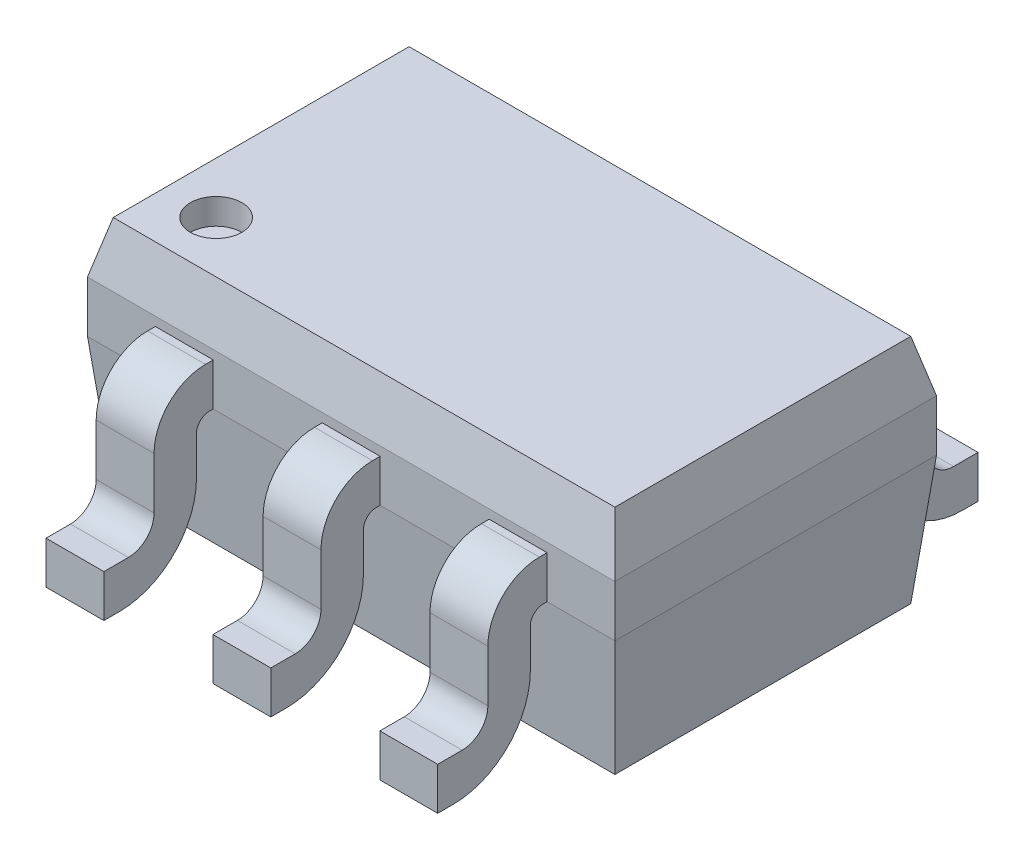
from build123d import *

# Parameters (mm, degrees)
SKETCH1_W             = 2.05
SKETCH1_H             = 1.25
BOSS_EXTRUDE1_DEPTH   = 0.9
BOSS_EXTRUDE2_START   = -1.025
BOSS_EXTRUDE2_DEPTH   = 0.76125
BOSS_EXTRUDE2_2_DEPTH = 0.76125
SKETCH3_W             = 0.42375
SKETCH3_H             = 0.425
CUT_EXTRUDE2_DEPTH    = 0.9
CHAMFER1_SIZE         = 0.05
CHAMFER1_SIZE2        = 0.5
CHAMFER2_SIZE         = 0.2
CHAMFER2_SIZE2        = 0.05
CHAMFER2_PART_2_SIZE  = 0.2
CHAMFER2_PART_2_SIZE2 = 0.05
CHAMFER2_PART_3_SIZE  = 0.2
CHAMFER2_PART_3_SIZE2 = 0.05
CHAMFER2_PART_4_SIZE  = 0.2
CHAMFER2_PART_4_SIZE2 = 0.05
SKETCH4_R             = 0.1
CUT_EXTRUDE3_DEPTH    = 0.1


with BuildPart() as part:
    # Sketch1 → Boss-Extrude1 (new body)
    with BuildSketch(Plane(origin=(0, 0, 0), x_dir=(1, 0, 0), z_dir=(0, 1, 0))):
        Rectangle(SKETCH1_W, SKETCH1_H)
    extrude(amount=BOSS_EXTRUDE1_DEPTH)

    # Chamfer1
    chamfer1_edges = [part.edges().sort_by_distance(p)[0] for p in [
        (0, 0, 0.625),
        (-1.025, 0, 0),
        (0, 0, -0.625),
        (1.025, 0, 0),
    ]]
    chamfer1_side = [part.faces().sort_by_distance(p)[0] for p in [
        (0, 0, 0),
    ]]
    chamfer(chamfer1_edges, length=CHAMFER1_SIZE, length2=CHAMFER1_SIZE2, reference=chamfer1_side[0])

    # Chamfer2
    chamfer2_edges = [part.edges().sort_by_distance(p)[0] for p in [
        (-1.025, 0.9, 0),
    ]]
    chamfer2_side = [part.faces().sort_by_distance(p)[0] for p in [
        (-1.025, 0.7, 0),
    ]]
    chamfer(chamfer2_edges, length=CHAMFER2_SIZE, length2=CHAMFER2_SIZE2, reference=chamfer2_side[0])

    # Chamfer2 part 2
    chamfer2_part_2_edges = [part.edges().sort_by_distance(p)[0] for p in [
        (0, 0.9, 0.625),
    ]]
    chamfer2_part_2_side = [part.faces().sort_by_distance(p)[0] for p in [
        (0, 0.7, 0.625),
    ]]
    chamfer(chamfer2_part_2_edges, length=CHAMFER2_PART_2_SIZE, length2=CHAMFER2_PART_2_SIZE2, reference=chamfer2_part_2_side[0])

    # Chamfer2 part 3
    chamfer2_part_3_edges = [part.edges().sort_by_distance(p)[0] for p in [
        (1.025, 0.9, 0),
    ]]
    chamfer2_part_3_side = [part.faces().sort_by_distance(p)[0] for p in [
        (1.025, 0.7, 0),
    ]]
    chamfer(chamfer2_part_3_edges, length=CHAMFER2_PART_3_SIZE, length2=CHAMFER2_PART_3_SIZE2, reference=chamfer2_part_3_side[0])

    # Chamfer2 part 4
    chamfer2_part_4_edges = [part.edges().sort_by_distance(p)[0] for p in [
        (0, 0.9, -0.625),
    ]]
    chamfer2_part_4_side = [part.faces().sort_by_distance(p)[0] for p in [
        (0, 0.7, -0.625),
    ]]
    chamfer(chamfer2_part_4_edges, length=CHAMFER2_PART_4_SIZE, length2=CHAMFER2_PART_4_SIZE2, reference=chamfer2_part_4_side[0])

    # Sketch4 → Cut-Extrude3 (cut)
    with BuildSketch(Plane(origin=(0, 0.9, 0), x_dir=(1, 0, 0), z_dir=(0, 1, 0))):
        with Locations((-0.775, -0.375)):
            Circle(SKETCH4_R)
    extrude(amount=-CUT_EXTRUDE3_DEPTH, mode=Mode.SUBTRACT)


with BuildPart() as body_2:
    # Sketch2 → Boss-Extrude2 (new body, symmetric)
    with BuildSketch(Plane(origin=(1.025, 0, 0), x_dir=(0, 0, -1), z_dir=(1, 0, 0)).offset(BOSS_EXTRUDE2_START)):
        with BuildLine():
            Line((-0.625, 0.665), (-0.655, 0.665))
            ThreePointArc((-0.655, 0.665), (-0.796421356, 0.606421356), (-0.855, 0.465))
            Line((-0.855, 0.465), (-0.855, 0.265))
            ThreePointArc((-0.855, 0.265), (-0.884289322, 0.194289322), (-0.955, 0.165))
            Line((-0.955, 0.165), (-1.05, 0.165))
            Line((-1.05, 0.165), (-1.05, 0))
            Line((-1.05, 0), (-0.99, 0))
            ThreePointArc((-0.99, 0), (-0.777867966, 0.087867966), (-0.69, 0.3))
            Line((-0.69, 0.3), (-0.69, 0.45))
            ThreePointArc((-0.69, 0.45), (-0.675355339, 0.485355339), (-0.64, 0.5))
            Line((-0.64, 0.5), (-0.625, 0.5))
            Line((-0.625, 0.5), (-0.625, 0.665))
        make_face()
    extrude(amount=BOSS_EXTRUDE2_DEPTH, both=True)


with BuildPart() as body_3:
    # Sketch2 → Boss-Extrude2 2 (new body, symmetric)
    with BuildSketch(Plane(origin=(1.025, 0, 0), x_dir=(0, 0, -1), z_dir=(1, 0, 0)).offset(BOSS_EXTRUDE2_START)):
        with BuildLine():
            Line((1.05, 0.165), (1.05, 0))
            Line((1.05, 0), (0.99, 0))
            ThreePointArc((0.99, 0), (0.777867966, 0.087867966), (0.69, 0.3))
            Line((0.69, 0.3), (0.69, 0.45))
            ThreePointArc((0.69, 0.45), (0.675355339, 0.485355339), (0.64, 0.5))
            Line((0.64, 0.5), (0.625, 0.5))
            Line((0.625, 0.5), (0.625, 0.665))
            Line((0.625, 0.665), (0.655, 0.665))
            ThreePointArc((0.655, 0.665), (0.796421356, 0.606421356), (0.855, 0.465))
            Line((0.855, 0.465), (0.855, 0.265))
            ThreePointArc((0.855, 0.265), (0.884289322, 0.194289322), (0.955, 0.165))
            Line((0.955, 0.165), (1.05, 0.165))
        make_face()
    extrude(amount=BOSS_EXTRUDE2_2_DEPTH, both=True)


with BuildPart() as cut_extrude2_tool:
    # Sketch3 → Cut-Extrude2 (new body)
    with BuildSketch(Plane(origin=(0, 0.9, 0), x_dir=(1, 0, 0), z_dir=(0, 1, 0))):
        with Locations((-0.324375, 0.8375)):
            Rectangle(SKETCH3_W, SKETCH3_H)
        with Locations((0.324375, 0.8375)):
            Rectangle(SKETCH3_W, SKETCH3_H)
        with Locations((0.324375, -0.8375)):
            Rectangle(SKETCH3_W, SKETCH3_H)
        with Locations((-0.324375, -0.8375)):
            Rectangle(SKETCH3_W, SKETCH3_H)
    extrude(amount=-CUT_EXTRUDE2_DEPTH)


with BuildPart() as body_2_1:
    add(body_2.part)

    # Cut-Extrude2: cut by cut_extrude2_tool
    add(cut_extrude2_tool.part, mode=Mode.SUBTRACT)


with BuildPart() as body_3_1:
    add(body_3.part)

    # Cut-Extrude2: cut by cut_extrude2_tool
    add(cut_extrude2_tool.part, mode=Mode.SUBTRACT)


solid = Compound([part.part, body_2_1.part, body_3_1.part])
